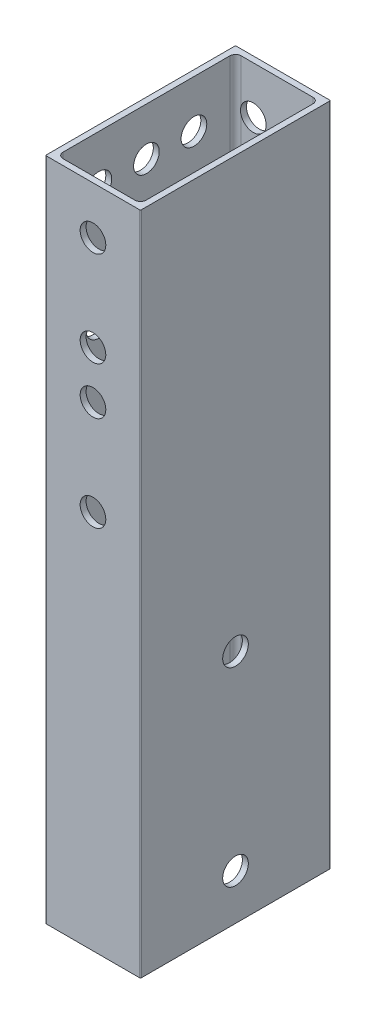
from build123d import *

# Parameters (mm, degrees)
BOSS_EXTRUDE1_DEPTH = 177.8
SKETCH2_R           = 10.16
SKETCH2_R_2         = 3.429
CUT_EXTRUDE1_DEPTH  = 12.7
SKETCH2_3_R         = 3.429
CUT_EXTRUDE2_DEPTH  = 26.4
CUT_EXTRUDE3_START  = -1.5875
SKETCH3_R           = 3.429
CUT_EXTRUDE3_DEPTH  = 50.2125
SKETCH4_R           = 3.429
CUT_EXTRUDE4_DEPTH  = 2.54


with BuildPart() as part:
    # Sketch1 → Boss-Extrude1 (new body)
    with BuildSketch(Plane(origin=(0, 0, 0), x_dir=(1, 0, 0), z_dir=(0, 1, 0))):
        with BuildLine():
            Line((0.254, 50.8), (25.146, 50.8))
            ThreePointArc((25.146, 50.8), (25.325605122, 50.725605122), (25.4, 50.546))
            Line((25.4, 50.546), (25.4, 0.254))
            ThreePointArc((25.4, 0.254), (25.325605122, 0.074394878), (25.146, 0))
            Line((25.146, 0), (0.254, 0))
            ThreePointArc((0.254, 0), (0.074394878, 0.074394878), (0, 0.254))
            Line((0, 0.254), (0, 50.546))
            ThreePointArc((0, 50.546), (0.074394878, 50.725605122), (0.254, 50.8))
        make_face()
        with BuildLine():
            Line((1.5875, 3.1115), (1.5875, 47.6885))
            ThreePointArc((1.5875, 47.6885), (2.033869265, 48.766130735), (3.1115, 49.2125))
            Line((3.1115, 49.2125), (22.2885, 49.2125))
            ThreePointArc((22.2885, 49.2125), (23.366130735, 48.766130735), (23.8125, 47.6885))
            Line((23.8125, 47.6885), (23.8125, 3.1115))
            ThreePointArc((23.8125, 3.1115), (23.366130735, 2.033869265), (22.2885, 1.5875))
            Line((22.2885, 1.5875), (3.1115, 1.5875))
            ThreePointArc((3.1115, 1.5875), (2.033869265, 2.033869265), (1.5875, 3.1115))
        make_face(mode=Mode.SUBTRACT)
    extrude(amount=BOSS_EXTRUDE1_DEPTH)

    # Sketch2 → Cut-Extrude1 (cut)
    with BuildSketch(Plane.ZY):
        with Locations((-25.4, 12.192)):
            Circle(SKETCH2_R)
        with Locations((-25.4, 12.192)):
            Circle(SKETCH2_R_2, mode=Mode.SUBTRACT)
        with Locations((-25.4, 62.992)):
            Circle(SKETCH2_R)
        with Locations((-25.4, 62.992)):
            Circle(SKETCH2_R_2, mode=Mode.SUBTRACT)
        with Locations((-38.1, 165.1)):
            Circle(SKETCH2_R_2)
        with Locations((-25.4, 165.1)):
            Circle(SKETCH2_R_2)
        with Locations((-12.7, 165.1)):
            Circle(SKETCH2_R_2)
        with Locations((-25.4, 133.35)):
            Circle(SKETCH2_R_2)
        with Locations((-12.7, 133.35)):
            Circle(SKETCH2_R_2)
        with Locations((-25.4, 101.6)):
            Circle(SKETCH2_R_2)
        with Locations((-12.7, 101.6)):
            Circle(SKETCH2_R_2)
        with Locations((-38.1, 133.35)):
            Circle(SKETCH2_R_2)
        with Locations((-38.1, 101.6)):
            Circle(SKETCH2_R_2)
    extrude(amount=-CUT_EXTRUDE1_DEPTH, mode=Mode.SUBTRACT)

    # Sketch2_3 → Cut-Extrude2 (cut, through all)
    with BuildSketch(Plane.ZY):
        with Locations((-25.4, 12.192)):
            Circle(SKETCH2_3_R)
        with Locations((-25.4, 62.992)):
            Circle(SKETCH2_3_R)
    extrude(amount=-CUT_EXTRUDE2_DEPTH, mode=Mode.SUBTRACT)

    # Sketch3 → Cut-Extrude3 (cut, through all)
    with BuildSketch(Plane.XY.offset(CUT_EXTRUDE3_START)):
        with Locations((19.05, 165.1)):
            Circle(SKETCH3_R)
        with Locations((6.35, 165.1)):
            Circle(SKETCH3_R)
        with Locations((6.35, 133.35)):
            Circle(SKETCH3_R)
        with Locations((6.35, 101.6)):
            Circle(SKETCH3_R)
        with Locations((19.05, 133.35)):
            Circle(SKETCH3_R)
        with Locations((19.05, 101.6)):
            Circle(SKETCH3_R)
    extrude(amount=-CUT_EXTRUDE3_DEPTH, mode=Mode.SUBTRACT)

    # Sketch4 → Cut-Extrude4 (cut)
    with BuildSketch(Plane.XY):
        with Locations((12.7, 165.1)):
            Circle(SKETCH4_R)
        with Locations((12.7, 139.7)):
            Circle(SKETCH4_R)
        with Locations((12.7, 101.6)):
            Circle(SKETCH4_R)
        with Locations((12.7, 127)):
            Circle(SKETCH4_R)
    extrude(amount=-CUT_EXTRUDE4_DEPTH, mode=Mode.SUBTRACT)


solid = part.part
